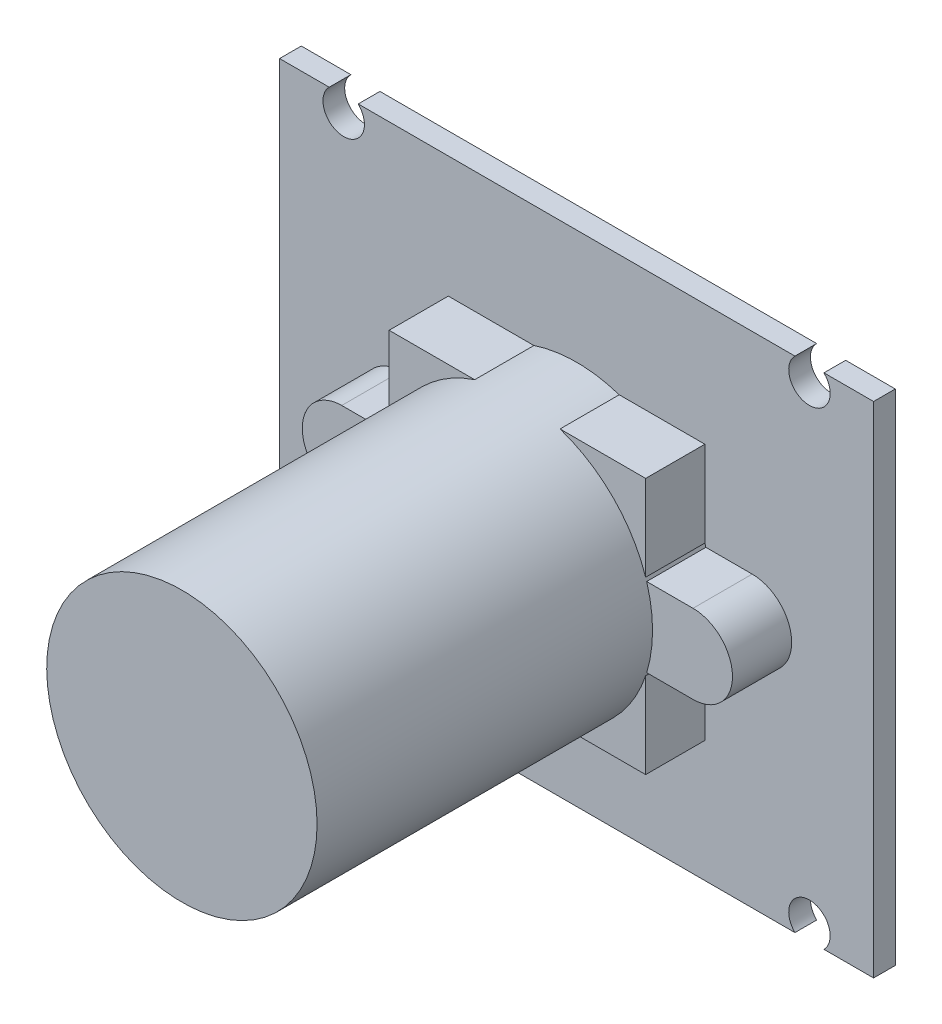
from build123d import *

# Parameters (mm, degrees)
SKETCH1_W           = 30.1
SKETCH1_H           = 25.3
BOSS_EXTRUDE1_DEPTH = 1.1
SKETCH2_R           = 1.05
CUT_EXTRUDE1_DEPTH  = 2.1
SKETCH3_W           = 13
SKETCH3_H           = 13
BOSS_EXTRUDE2_DEPTH = 3
BOSS_EXTRUDE3_DEPTH = 3
SKETCH5_R           = 6.85
BOSS_EXTRUDE4_DEPTH = 20


with BuildPart() as part:
    # Sketch1 → Boss-Extrude1 (new body)
    with BuildSketch(Plane.XY):
        Rectangle(SKETCH1_W, SKETCH1_H)
    extrude(amount=BOSS_EXTRUDE1_DEPTH)

    # Sketch2 → Cut-Extrude1 (cut, through all)
    with BuildSketch(Plane.XY.offset(1.1)):
        with Locations((-11.8, 11.9)):
            Circle(SKETCH2_R)
        with Locations((11.8, 11.9)):
            Circle(SKETCH2_R)
        with Locations((11.8, -11.9)):
            Circle(SKETCH2_R)
        with Locations((-11.8, -11.9)):
            Circle(SKETCH2_R)
    extrude(amount=-CUT_EXTRUDE1_DEPTH, mode=Mode.SUBTRACT)

    # Sketch3 → Boss-Extrude2 (add)
    with BuildSketch(Plane.XY.offset(1.1)):
        Rectangle(SKETCH3_W, SKETCH3_H)
    extrude(amount=BOSS_EXTRUDE2_DEPTH)

    # Sketch4 → Boss-Extrude3 (add)
    with BuildSketch(Plane.XY.offset(1.1)):
        with BuildLine():
            Line((-8.9, 2), (8.9, 2))
            ThreePointArc((8.9, 2), (10.9, 0), (8.9, -2))
            Line((8.9, -2), (-8.9, -2))
            ThreePointArc((-8.9, -2), (-10.9, 0), (-8.9, 2))
        make_face()
    extrude(amount=BOSS_EXTRUDE3_DEPTH)

    # Sketch5 → Boss-Extrude4 (add)
    with BuildSketch(Plane.XY.offset(1.1)):
        Circle(SKETCH5_R)
    extrude(amount=BOSS_EXTRUDE4_DEPTH)


solid = part.part
